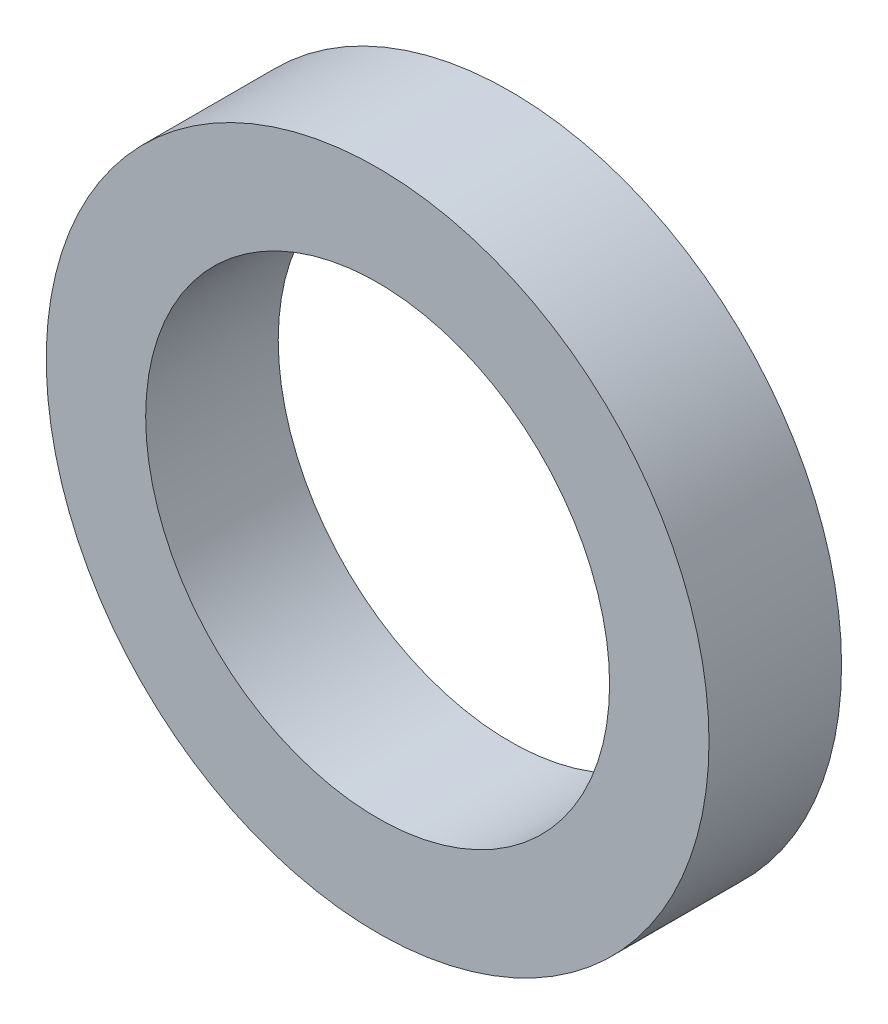
from build123d import *

# Parameters (mm, degrees)
CROQUIS4_R              = 35
SALIENTE_EXTRUIR2_DEPTH = 14
CROQUIS5_R              = 24.5
CORTAR_EXTRUIR2_DEPTH   = 14


with BuildPart() as part:
    # Croquis4 → Saliente-Extruir2 (new body)
    with BuildSketch(Plane.XY):
        Circle(CROQUIS4_R)
    extrude(amount=SALIENTE_EXTRUIR2_DEPTH)

    # Croquis5 → Cortar-Extruir2 (cut)
    with BuildSketch(Plane.XY):
        Circle(CROQUIS5_R)
    extrude(amount=CORTAR_EXTRUIR2_DEPTH, mode=Mode.SUBTRACT)


solid = part.part
